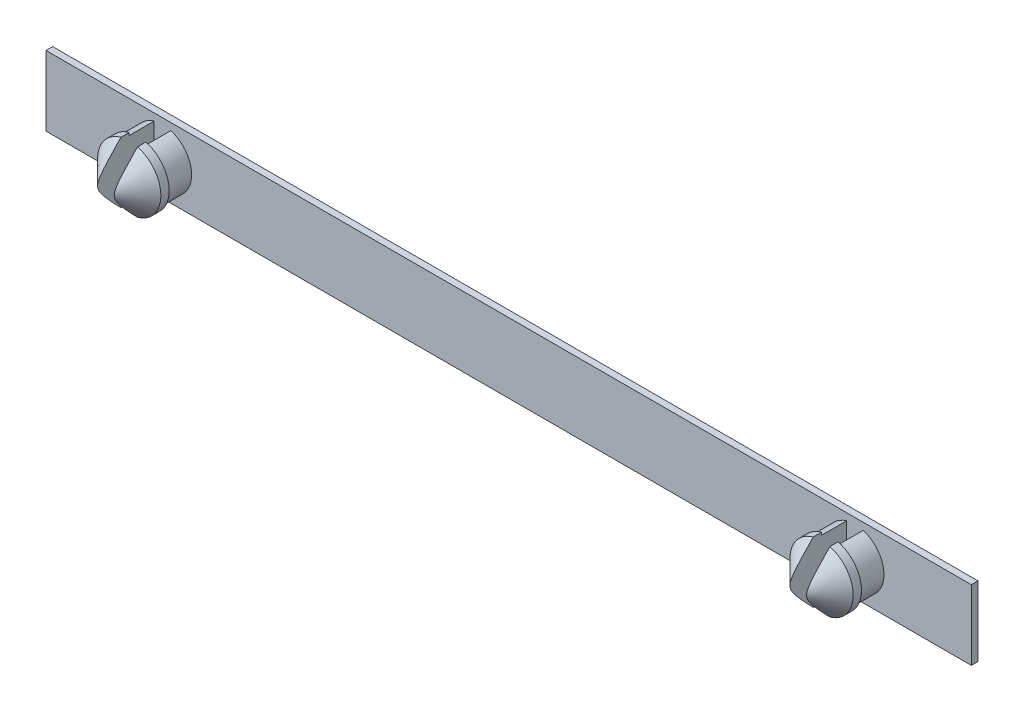
from build123d import *

# Parameters (mm, degrees)
SKICA2_W                 = 55.6
SKICA2_H                 = 4.2
P_IDAT_VYSUNUT_M2_DEPTH  = 0.4
SKICA3_R                 = 1.75
P_IDAT_VYSUNUT_M3_DEPTH  = 1.5
SKICA5_R                 = 1.9
P_IDAT_VYSUNUT_M5_DEPTH  = 2
ZKOSEN_2_SIZE            = 1.5
SKICA7_W                 = 1
SKICA7_H                 = 5
ODEBRAT_VYSUNUT_M1_DEPTH = 3.5


with BuildPart() as part:
    # Skica2 → Přidat vysunutím2 (new body)
    with BuildSketch(Plane.XY):
        Rectangle(SKICA2_W, SKICA2_H)
    extrude(amount=P_IDAT_VYSUNUT_M2_DEPTH)

    # Skica3 → Přidat vysunutím3 (add)
    with BuildSketch(Plane.XY.offset(0.4)):
        with Locations((-20.8, 0)):
            Circle(SKICA3_R)
        with Locations((20.8, 0)):
            Circle(SKICA3_R)
    extrude(amount=P_IDAT_VYSUNUT_M3_DEPTH)

    # Skica5 → Přidat vysunutím5 (add)
    with BuildSketch(Plane.XY.offset(1.9)):
        with Locations((-20.8, 0)):
            Circle(SKICA5_R)
        with Locations((20.8, 0)):
            Circle(SKICA5_R)
    extrude(amount=P_IDAT_VYSUNUT_M5_DEPTH)

    # Zkosení2
    zkosen_2_edges = [part.edges().sort_by_distance(p)[0] for p in [
        (-22.7, 0, 3.9),
        (18.9, 0, 3.9),
    ]]
    chamfer(zkosen_2_edges, length=ZKOSEN_2_SIZE)

    # Skica7 → Odebrat vysunutím1 (cut)
    with BuildSketch(Plane.XY.offset(3.9)):
        with Locations((-20.8, 0)):
            Rectangle(SKICA7_W, SKICA7_H)
        with Locations((20.8, 0)):
            Rectangle(SKICA7_W, SKICA7_H)
    extrude(amount=-ODEBRAT_VYSUNUT_M1_DEPTH, mode=Mode.SUBTRACT)


solid = part.part
